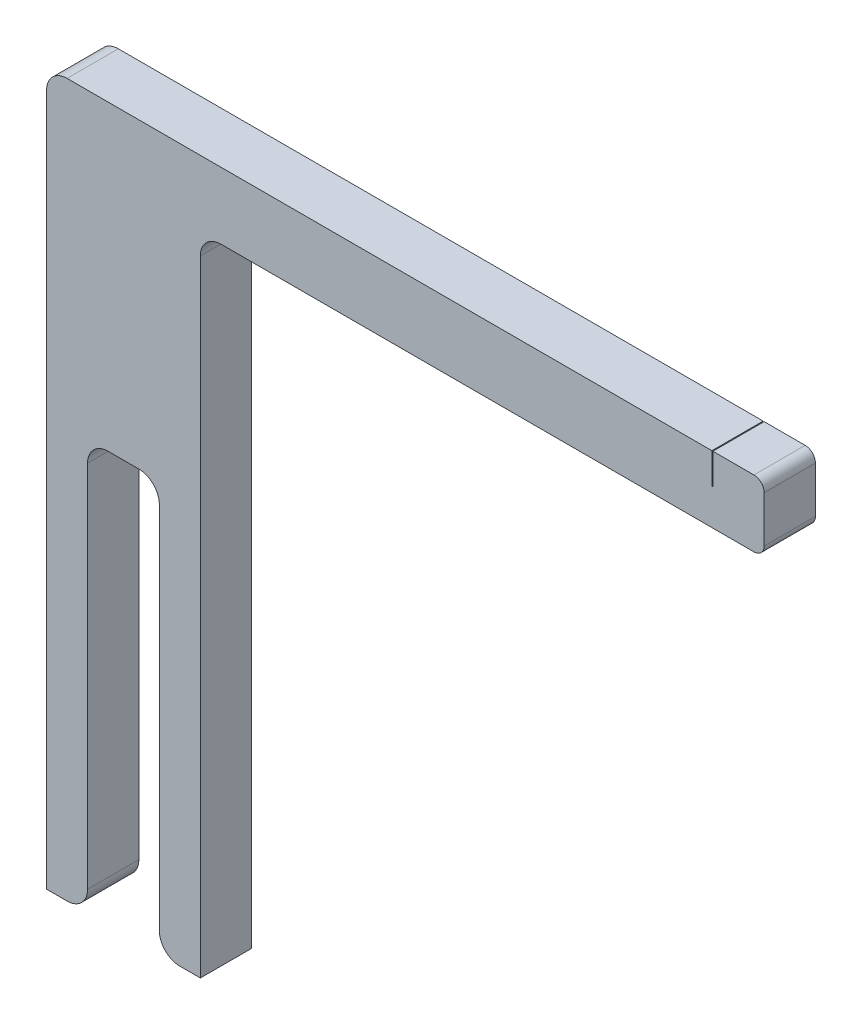
from build123d import *

# Parameters (mm, degrees)
BOSS_EXTRUDE1_DEPTH = 5
SKETCH3_W           = 0.1
SKETCH3_H           = 5
CUT_EXTRUDE1_DEPTH  = 3
FILLET1_R           = 2


with BuildPart() as part:
    # Sketch1 → Boss-Extrude1 (new body)
    with BuildSketch(Plane.XY):
        with BuildLine():
            Line((0, 0), (0, 67.5))
            ThreePointArc((0, 67.5), (0.585786438, 68.914213562), (2, 69.5))
            Line((2, 69.5), (69, 69.5))
            ThreePointArc((69, 69.5), (69.707106781, 69.207106781), (70, 68.5))
            Line((70, 68.5), (70, 64))
            ThreePointArc((70, 64), (69.707106781, 63.292893219), (69, 63))
            Line((69, 63), (17, 63))
            ThreePointArc((17, 63), (15.585786438, 62.414213562), (15, 61))
            Line((15, 61), (15, 0))
            Line((15, 0), (11, 0))
            Line((11, 0), (11, 40))
            Line((11, 40), (4, 40))
            Line((4, 40), (4, 0))
            Line((4, 0), (0, 0))
        make_face()
    extrude(amount=BOSS_EXTRUDE1_DEPTH)

    # Sketch3 → Cut-Extrude1 (cut)
    with BuildSketch(Plane(origin=(0, 69.5, 0), x_dir=(1, 0, 0), z_dir=(0, 1, 0))):
        with Locations((64.95, -2.5)):
            Rectangle(SKETCH3_W, SKETCH3_H)
    extrude(amount=-CUT_EXTRUDE1_DEPTH, mode=Mode.SUBTRACT)

    # Fillet1
    fillet1_edges = [part.edges().sort_by_distance(p)[0] for p in [
        (11, 0, 2.5),
        (11, 40, 2.5),
        (4, 40, 2.5),
        (4, 0, 2.5),
    ]]
    fillet(fillet1_edges, radius=FILLET1_R)


solid = part.part
